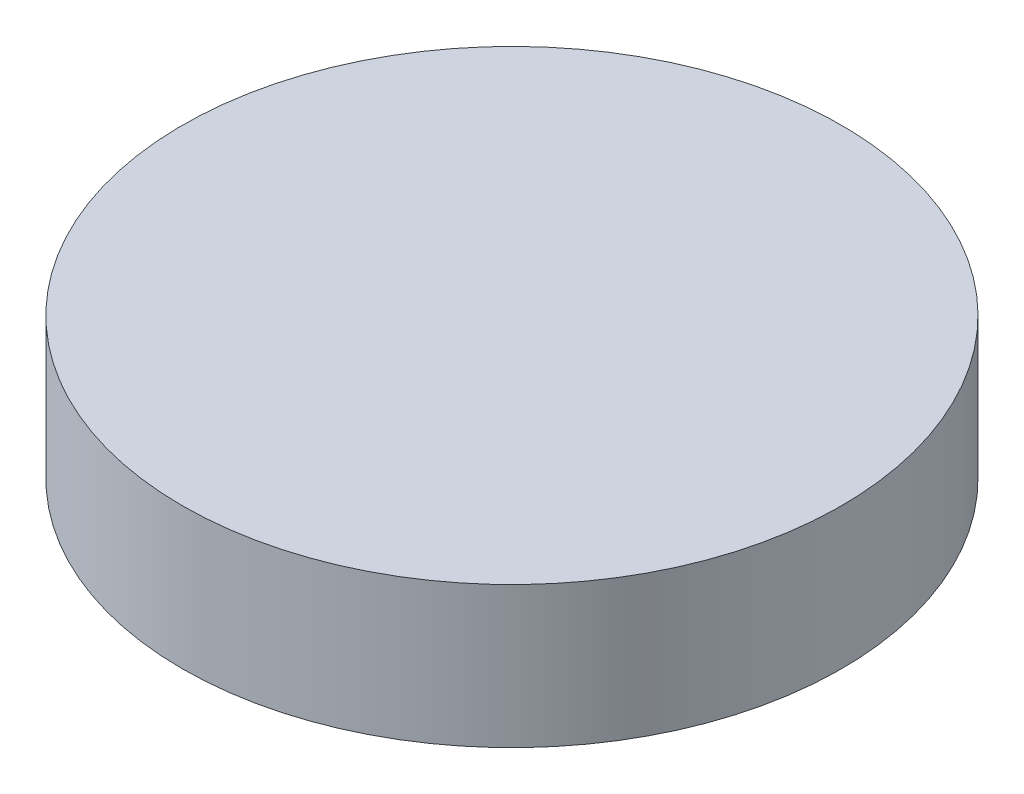
from build123d import *

# Parameters (mm, degrees)
SKETCH1_R           = 14
BOSS_EXTRUDE1_DEPTH = 6


with BuildPart() as part:
    # Sketch1 → Boss-Extrude1 (new body)
    with BuildSketch(Plane(origin=(0, 0, 0), x_dir=(1, 0, 0), z_dir=(0, 1, 0))):
        Circle(SKETCH1_R)
    extrude(amount=BOSS_EXTRUDE1_DEPTH)


solid = part.part
